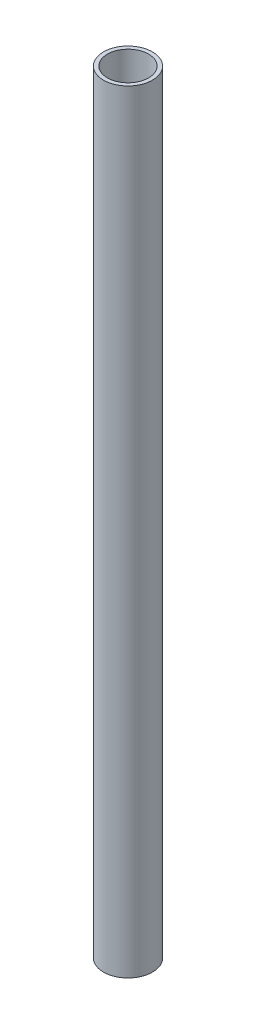
from build123d import *

# Parameters (mm, degrees)
SKETCH1_R           = 24.13
SKETCH1_R_2         = 20.32
BOSS_EXTRUDE1_DEPTH = 761.0475


with BuildPart() as part:
    # Sketch1 → Boss-Extrude1 (new body)
    with BuildSketch(Plane(origin=(0, 0, 0), x_dir=(1, 0, 0), z_dir=(0, 1, 0))):
        Circle(SKETCH1_R)
        Circle(SKETCH1_R_2, mode=Mode.SUBTRACT)
    extrude(amount=BOSS_EXTRUDE1_DEPTH)


solid = part.part
